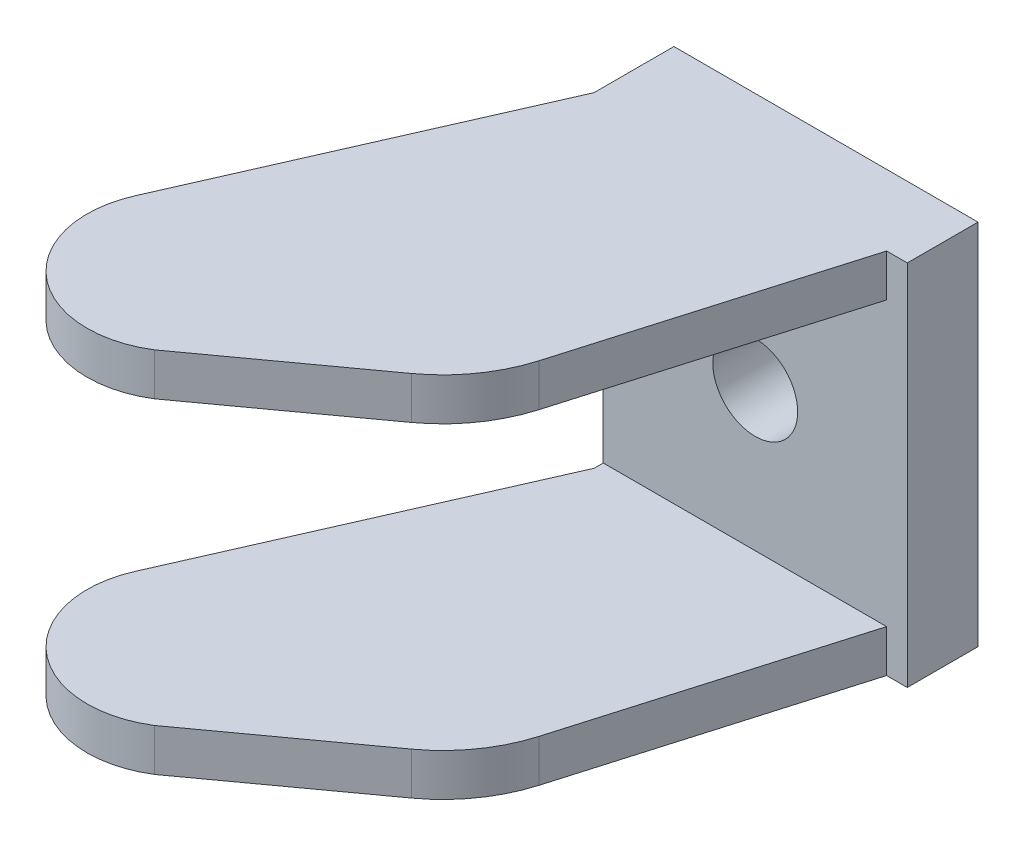
from build123d import *

# Parameters (mm, degrees)
BOSS_EXTRUDE1_DEPTH = 13
CUT_EXTRUDE1_DEPTH  = 10
SKETCH4_W           = 21.5
SKETCH4_H           = 26
BOSS_EXTRUDE2_DEPTH = 5
SKETCH5_R           = 3
CUT_EXTRUDE2_DEPTH  = 46.55491192


with BuildPart() as part:
    # Sketch1 → Boss-Extrude1 (new, symmetric)
    with BuildSketch(Plane(origin=(0, 0, 0), x_dir=(1, 0, 0), z_dir=(0, 1, 0))):
        with BuildLine():
            Line((0, 0), (21.5, 0))
            Line((21.5, 0), (14.467721765, -24.012898335))
            ThreePointArc((14.467721765, -24.012898335), (13.043725458, -26.964613514), (10.741924274, -29.297444262))
            Line((10.741924274, -29.297444262), (0.20999258, -36.935988128))
            ThreePointArc((0.20999258, -36.935988128), (-8.079954607, -36.293771416), (-9.907897405, -28.182403357))
            Line((-9.907897405, -28.182403357), (0, -5.649444205))
            Line((0, -5.649444205), (0, 0))
        make_face()
    extrude(amount=BOSS_EXTRUDE1_DEPTH, both=True)

    # Sketch1_2 → Cut-Extrude1 (cut, symmetric)
    with BuildSketch(Plane(origin=(0, 0, 0), x_dir=(1, 0, 0), z_dir=(0, 1, 0))):
        with BuildLine():
            Line((0, 0), (21.5, 0))
            Line((21.5, 0), (14.467721765, -24.012898335))
            ThreePointArc((14.467721765, -24.012898335), (13.043725458, -26.964613514), (10.741924274, -29.297444262))
            Line((10.741924274, -29.297444262), (0.20999258, -36.935988128))
            ThreePointArc((0.20999258, -36.935988128), (-8.079954607, -36.293771416), (-9.907897405, -28.182403357))
            Line((-9.907897405, -28.182403357), (0, -5.649444205))
            Line((0, -5.649444205), (0, 0))
        make_face()
    extrude(amount=CUT_EXTRUDE1_DEPTH, both=True, mode=Mode.SUBTRACT)


with BuildPart() as cut_extrude1_piece_1:
    # of the separate pieces the step leaves, piece 1, a body of its own (cut_extrude1_pieces)
    add(part.part.solids().sort_by_distance((10.741924274, -13, 29.297444262))[0])



with BuildPart() as cut_extrude1_piece_2:
    # of the separate pieces the step leaves, piece 2, a body of its own (cut_extrude1_pieces)
    add(part.part.solids().sort_by_distance((10.741924274, 10, 29.297444262))[0])


with BuildPart() as cut_extrude1_piece_1_1:
    add(cut_extrude1_piece_1.part)

    add(cut_extrude1_piece_2.part)  # Boss-Extrude2 merges Cut-Extrude1 piece 2
    # Sketch4 → Boss-Extrude2 (add)
    with BuildSketch(Plane(origin=(0, 0, 0), x_dir=(-1, 0, 0), z_dir=(0, 0, -1))):
        with Locations((-10.75, 0)):
            Rectangle(SKETCH4_W, SKETCH4_H)
    extrude(amount=-BOSS_EXTRUDE2_DEPTH)

    # Sketch5 → Cut-Extrude2 (cut, through all)
    with BuildSketch(Plane(origin=(0, 0, 0), x_dir=(-1, 0, 0), z_dir=(0, 0, -1))):
        with Locations((-10.75, 0)):
            Circle(SKETCH5_R)
    extrude(amount=-CUT_EXTRUDE2_DEPTH, mode=Mode.SUBTRACT)


solid = cut_extrude1_piece_1_1.part
